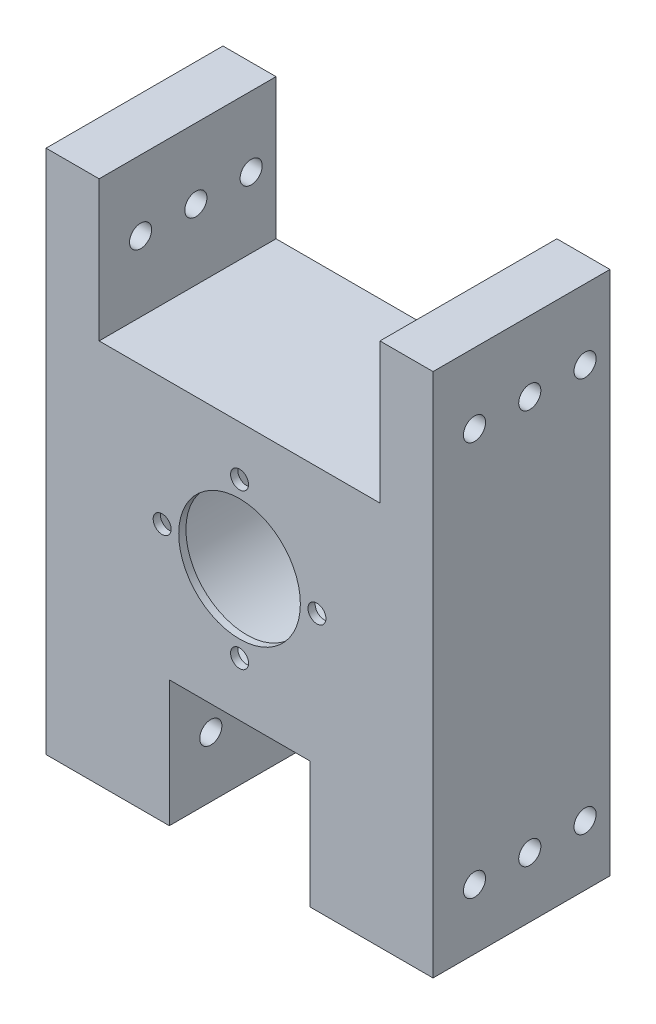
from build123d import *

# Parameters (mm, degrees)
SKETCH1_R               = 11
BOSS_EXTRUDE1_DEPTH     = 55
SKETCH2_R               = 18
CUT_EXTRUDE1_DEPTH      = 53.7
SKETCH4_R               = 1.625
CUT_EXTRUDE2_DEPTH      = 56
SKETCH5_R               = 2
CUT_EXTRUDE3_DEPTH      = 36
CUT_EXTRUDE3_DEPTH_BACK = 36
CUT_EXTRUDE4_DEPTH      = 74


with BuildPart() as part:
    # Sketch1 → Boss-Extrude1 (new body)
    with BuildSketch(Plane.XY):
        Polygon((-12.7, -23.74), (12.7, -23.74), (12.7, -46.6), (35, -46.6), (35, -20), (35, 48.4), (25.4, 48.4), (25.4, 23), (-25.4, 23), (-25.4, 48.4), (-35, 48.4), (-35, -24.5), (-35, -46.6), (-12.7, -46.6), align=None)
        Circle(SKETCH1_R, mode=Mode.SUBTRACT)
    extrude(amount=BOSS_EXTRUDE1_DEPTH)

    # Sketch2 → Cut-Extrude1 (cut)
    with BuildSketch(Plane(origin=(0, 0, 0), x_dir=(-1, 0, 0), z_dir=(0, 0, -1))):
        Circle(SKETCH2_R)
    extrude(amount=-CUT_EXTRUDE1_DEPTH, mode=Mode.SUBTRACT)

    # Sketch4 → Cut-Extrude2 (cut, through all)
    with BuildSketch(Plane.XY.offset(55)):
        with Locations((0, 14)):
            Circle(SKETCH4_R)
        with Locations((14, 0)):
            Circle(SKETCH4_R)
        with Locations((0, -14)):
            Circle(SKETCH4_R)
        with Locations((-14, 0)):
            Circle(SKETCH4_R)
    extrude(amount=-CUT_EXTRUDE2_DEPTH, mode=Mode.SUBTRACT)

    # Sketch5 → Cut-Extrude3 (cut, two sides)
    with BuildSketch(Plane(origin=(0, 0, 0), x_dir=(0, 0, -1), z_dir=(1, 0, 0))) as cut_extrude3_sk:
        with Locations((-27.5, -35.7)):
            Circle(SKETCH5_R)
        with Locations((-17.5, -35.7)):
            Circle(SKETCH5_R)
        with Locations((-7.5, -35.7)):
            Circle(SKETCH5_R)
        with Locations((-37.5, -35.7)):
            Circle(SKETCH5_R)
        with Locations((-47.5, -35.7)):
            Circle(SKETCH5_R)
        with Locations((-27.5, 35.7)):
            Circle(SKETCH5_R)
        with Locations((-37.5, 35.7)):
            Circle(SKETCH5_R)
        with Locations((-47.5, 35.7)):
            Circle(SKETCH5_R)
        with Locations((-17.5, 35.7)):
            Circle(SKETCH5_R)
        with Locations((-7.5, 35.7)):
            Circle(SKETCH5_R)
    extrude(amount=CUT_EXTRUDE3_DEPTH, mode=Mode.SUBTRACT)
    extrude(cut_extrude3_sk.sketch, amount=-CUT_EXTRUDE3_DEPTH_BACK, mode=Mode.SUBTRACT)

    # Sketch6 → Cut-Extrude4 (cut)
    with BuildSketch(Plane(origin=(35, 0, 0), x_dir=(0, 0, -1), z_dir=(1, 0, 0))):
        Polygon((-23, -1.1), (-23, 51.285793323), (26.639959918, 51.285793323), (26.639959918, -56.994126514), (-23, -56.994126514), align=None)
    extrude(amount=-CUT_EXTRUDE4_DEPTH, mode=Mode.SUBTRACT)


solid = part.part
